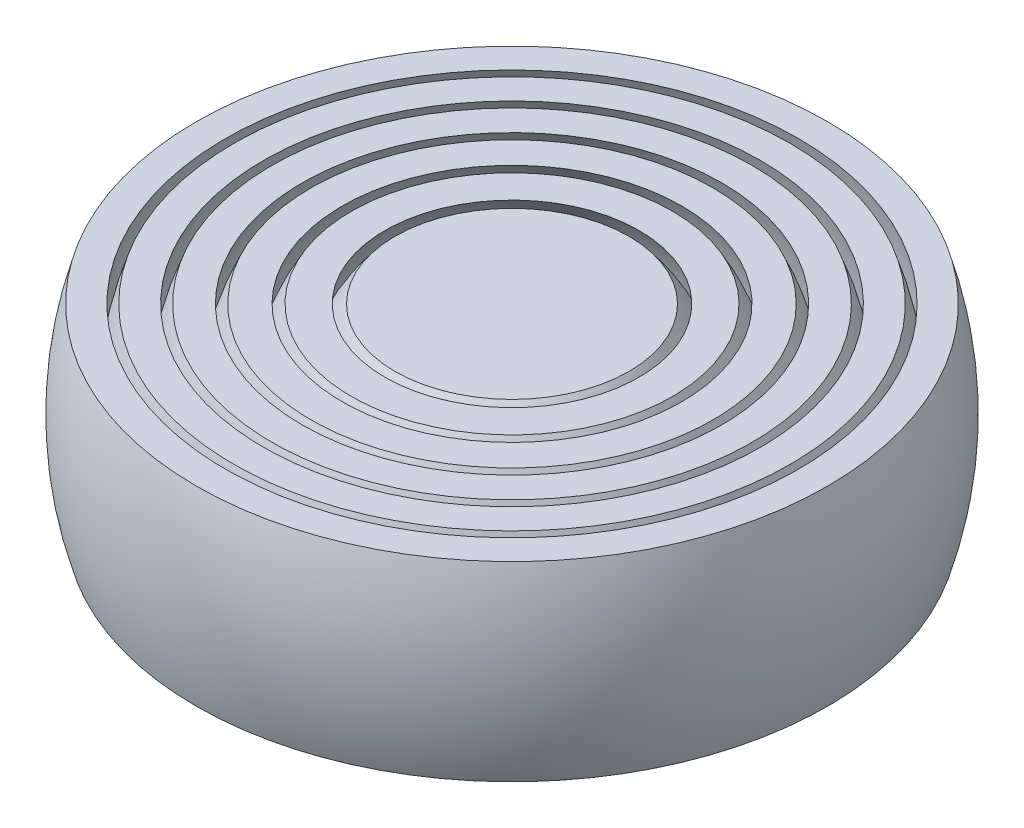
from build123d import *

# Parameters (mm, degrees)
SKETCH2_W               = 74.325343109
SKETCH2_H               = 24.095497766
SKETCH2_H_2             = 25.578297629
CUT_EXTRUDE1_DEPTH      = 21.75
CUT_EXTRUDE1_DEPTH_BACK = 21.75


with BuildPart() as part:
    # Sketch1 → Revolve2 (revolve)
    with BuildSketch(Plane.XY):
        with BuildLine():
            Line((0, 9.5), (0, -9.5))
            ThreePointArc((0, -9.5), (-9.5, 0), (0, 9.5))
        make_face()
        with BuildLine():
            Line((0, 11.75), (0, 10))
            ThreePointArc((0, 10), (-10, 0), (0, -10))
            Line((0, -10), (0, -11.75))
            ThreePointArc((0, -11.75), (-11.75, 0), (0, 11.75))
        make_face()
        with BuildLine():
            Line((0, 14), (0, 12.25))
            ThreePointArc((0, 12.25), (-12.25, 0), (0, -12.25))
            Line((0, -12.25), (0, -14))
            ThreePointArc((0, -14), (-14, 0), (0, 14))
        make_face()
        with BuildLine():
            Line((0, 16.25), (0, 14.5))
            ThreePointArc((0, 14.5), (-14.5, 0), (0, -14.5))
            Line((0, -14.5), (0, -16.25))
            ThreePointArc((0, -16.25), (-16.25, 0), (0, 16.25))
        make_face()
        with BuildLine():
            Line((0, 18.5), (0, 16.75))
            ThreePointArc((0, 16.75), (-16.75, 0), (0, -16.75))
            Line((0, -16.75), (0, -18.5))
            ThreePointArc((0, -18.5), (-18.5, 0), (0, 18.5))
        make_face()
        with BuildLine():
            Line((0, 20.75), (0, 19))
            ThreePointArc((0, 19), (-19, 0), (0, -19))
            Line((0, -19), (0, -20.75))
            ThreePointArc((0, -20.75), (-20.75, 0), (0, 20.75))
        make_face()
    revolve(axis=Axis((0, 9.5, 0), (0, -1, 0)))

    # Sketch2 → Cut-Extrude1 (cut, two sides)
    with BuildSketch(Plane.XY) as cut_extrude1_sk:
        with Locations((-0.278024974, 18.047748883)):
            Rectangle(SKETCH2_W, SKETCH2_H)
        with Locations((-0.278024974, -18.789148815)):
            Rectangle(SKETCH2_W, SKETCH2_H_2)
    extrude(amount=CUT_EXTRUDE1_DEPTH, mode=Mode.SUBTRACT)
    extrude(cut_extrude1_sk.sketch, amount=-CUT_EXTRUDE1_DEPTH_BACK, mode=Mode.SUBTRACT)


solid = part.part
